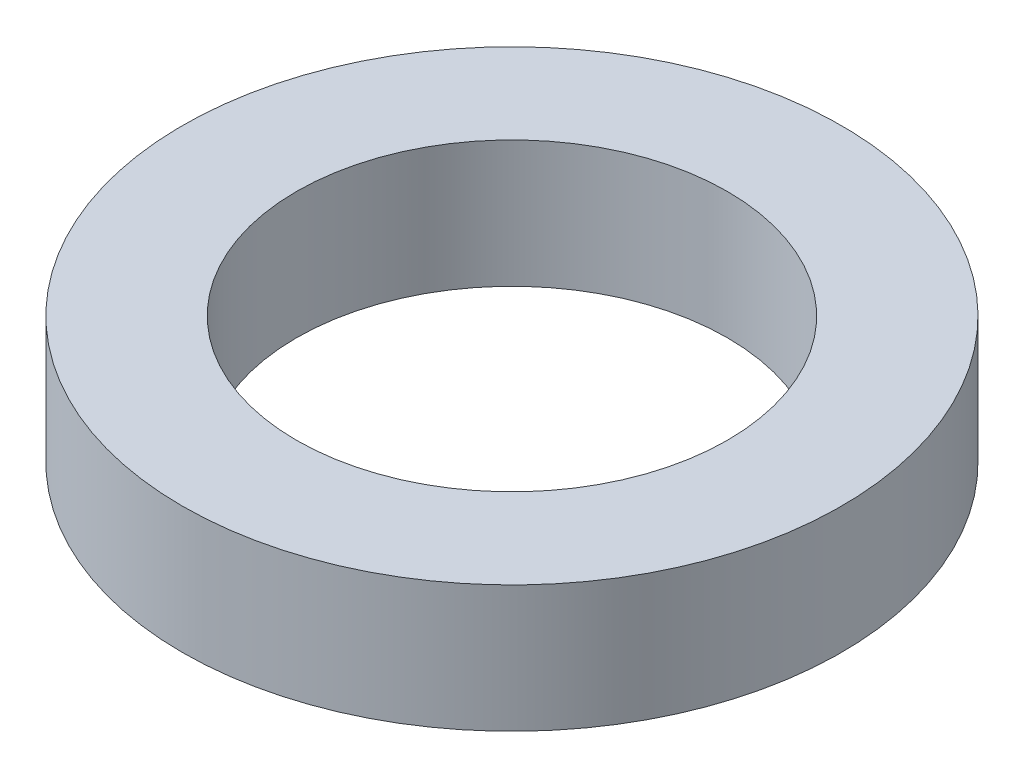
from build123d import *

# Parameters (mm, degrees)
SKETCH_1_R      = 13
SKETCH_1_R_2    = 8.5
EXTRUDE_1_DEPTH = 5


with BuildPart() as part:
    # 草图1 → 凸台-拉伸1 (new body)
    with BuildSketch(Plane(origin=(0, 0, 0), x_dir=(1, 0, 0), z_dir=(0, 1, 0))):
        Circle(SKETCH_1_R)
        Circle(SKETCH_1_R_2, mode=Mode.SUBTRACT)
    extrude(amount=EXTRUDE_1_DEPTH)


solid = part.part
